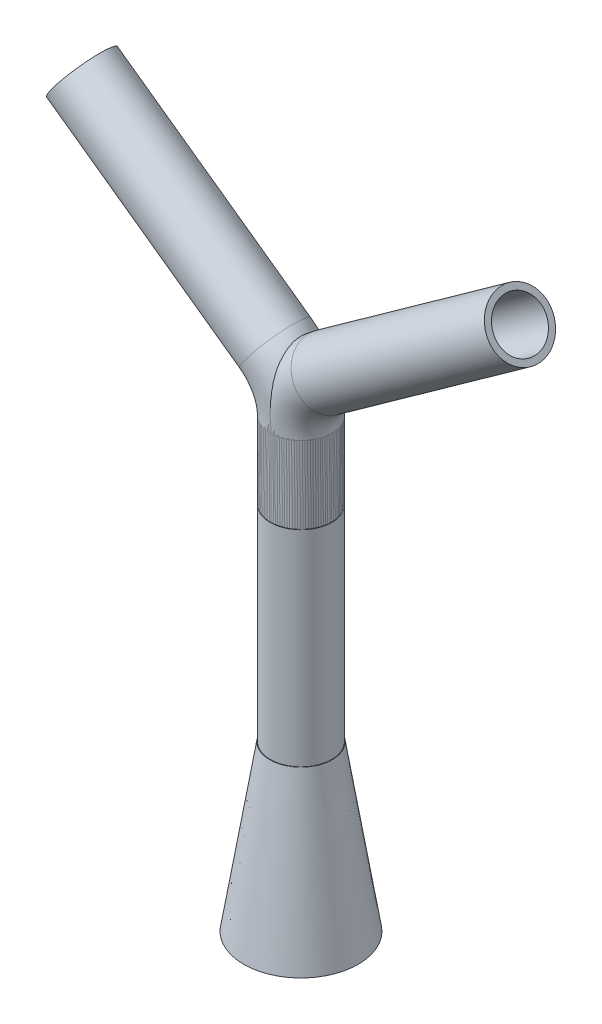
from build123d import *

# Parameters (mm, degrees)
SKETCH1_R               = 27.9
BOSS_EXTRUDE1_DEPTH     = 80
BOSS_EXTRUDE1_TAPER     = 9
SKETCH2_R               = 12
CUT_EXTRUDE1_DEPTH      = 80
CUT_EXTRUDE1_DRAFT      = 9
SWEEP_THIN1_PROFILE_R   = 15
SWEEP_THIN1_PROFILE_R_2 = 12
SWEEP_THIN3_PROFILE_R   = 15
SWEEP_THIN3_PROFILE_R_2 = 12
CIRPATTERN1_COUNT       = 2


with BuildPart() as part:
    # Sketch1 → Boss-Extrude1 (new body)
    with BuildSketch(Plane(origin=(0, -6028.96566858, 0), x_dir=(1, 0, 0), z_dir=(0, 1, 0))):
        with Locations((-22872.617683291, -40486.700195766)):
            Circle(SKETCH1_R)
    extrude(amount=BOSS_EXTRUDE1_DEPTH, taper=BOSS_EXTRUDE1_TAPER)


with BuildPart() as cut_extrude1_tool:
    # Sketch2 → Cut-Extrude1 (with draft: the straight prism first)
    with BuildSketch(Plane(origin=(0, -5948.96566858, 0), x_dir=(1, 0, 0), z_dir=(0, 1, 0))):
        with Locations((-22872.617683291, -40486.700195766)):
            Circle(SKETCH2_R)
    extrude(amount=-CUT_EXTRUDE1_DEPTH)
    # Cut-Extrude1: the draft: its side faces are tilted about the plane it starts from
    cut_extrude1_sides = [cut_extrude1_tool.faces().sort_by_distance(p)[0] for p in [
        (-22884.617683291, -5988.96566858, 40486.700195766),
    ]]
    draft(cut_extrude1_sides, Plane(origin=(0, -5948.96566858, 0), x_dir=(1, 0, 0), z_dir=(0, 1, 0)), CUT_EXTRUDE1_DRAFT)


with BuildPart() as part_1:
    add(part.part)

    # Cut-Extrude1: cut by cut_extrude1_tool
    add(cut_extrude1_tool.part, mode=Mode.SUBTRACT)

    # Sweep-Thin1: sweep along a curve in space
    with BuildLine() as sweep_thin1_path:
        Line((-22872.617683291, -5948.96566858, 40486.700195766), (-22872.617683291, -5848.96566858, 40486.700195766))
    # Sweep-Thin1 profile (on start of the path) → Sweep-Thin1 (sweep)
    with BuildSketch(Plane(origin=(-22872.617683291, -5948.96566858, 40486.700195766), x_dir=(0, 0, 1), z_dir=(0, 1, 0))):
        Circle(SWEEP_THIN1_PROFILE_R)
        Circle(SWEEP_THIN1_PROFILE_R_2, mode=Mode.SUBTRACT)
    sweep(path=sweep_thin1_path.line)


with BuildPart() as body_2:
    # Sweep-Thin3: sweep along a curve in space
    with BuildLine() as sweep_thin3_path:
        Line((-22885.16794187, -5786.960216658, 40486.700195766), (-22979.29712317, -5719.651700705, 40486.700195766))
        ThreePointArc((-22872.617683291, -5811.363219021, 40486.700195766), (-22875.93911284, -5797.64265494, 40486.700195766), (-22885.16794187, -5786.960216658, 40486.700195766))
        Line((-22872.617683291, -5848.785369489, 40486.700195766), (-22872.617683291, -5811.363219021, 40486.700195766))
    # Sweep-Thin3 profile (on start of the path) → Sweep-Thin3 (sweep)
    with BuildSketch(Plane(origin=(-22872.617683291, -5848.785369489, 40486.700195766), x_dir=(0, 0, 1), z_dir=(0, 1, 0))):
        Circle(SWEEP_THIN3_PROFILE_R)
        Circle(SWEEP_THIN3_PROFILE_R_2, mode=Mode.SUBTRACT)
    sweep(path=sweep_thin3_path.line)


with BuildPart() as cirpattern1_1:
    # CirPattern1: pattern copy
    add(body_2.part.rotate(Axis((-22872.617683291, -5848.96566858, 40486.700195766), (0, 1, 0)), 1 * 360 / CIRPATTERN1_COUNT))


solid = Compound([part_1.part, body_2.part, cirpattern1_1.part])
